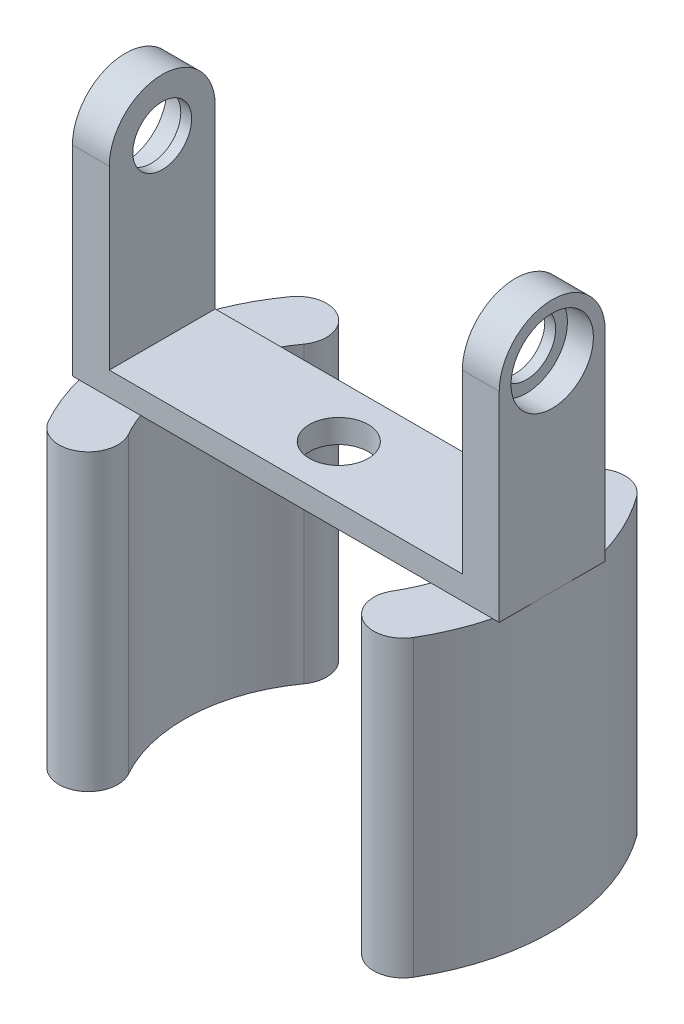
from build123d import *

# Parameters (mm, degrees)
SKETCH1_R           = 9
SKETCH1_R_2         = 5
BOSS_EXTRUDE1_DEPTH = 6.26
BOSS_EXTRUDE2_DEPTH = 6.26
SKETCH2_R           = 7
CUT_EXTRUDE1_DEPTH  = 4.41
SKETCH4_W           = 36.26
SKETCH4_H           = 18
BOSS_EXTRUDE3_DEPTH = 4
SKETCH5_R           = 5
CUT_EXTRUDE2_DEPTH  = 5
BOSS_EXTRUDE4_DEPTH = 50


with BuildPart() as part:
    # Sketch1 → Boss-Extrude1 (new body)
    with BuildSketch(Plane(origin=(0, 0, 0), x_dir=(0, 0, -1), z_dir=(1, 0, 0))):
        Circle(SKETCH1_R)
        Circle(SKETCH1_R_2, mode=Mode.SUBTRACT)
    extrude(amount=BOSS_EXTRUDE1_DEPTH)

    # Sketch3 → Boss-Extrude2 (add)
    with BuildSketch(Plane.ZY):
        with BuildLine():
            Line((-9, 0), (-9, -30))
            Line((-9, -30), (9, -30))
            Line((9, -30), (9, 0))
            Line((9, 0), (5, 0))
            ThreePointArc((5, 0), (0, -5), (-5, 0))
            Line((-5, 0), (-9, 0))
        make_face()
    extrude(amount=-BOSS_EXTRUDE2_DEPTH)

    # Sketch2 → Cut-Extrude1 (cut)
    with BuildSketch(Plane(origin=(6.26, 0, 0), x_dir=(0, 0, -1), z_dir=(1, 0, 0))):
        Circle(SKETCH2_R)
    extrude(amount=-CUT_EXTRUDE1_DEPTH, mode=Mode.SUBTRACT)

    # Sketch4 → Boss-Extrude3 (add)
    with BuildSketch(Plane.XZ.offset(30)):
        with Locations((-11.87, 0)):
            Rectangle(SKETCH4_W, SKETCH4_H)
    extrude(amount=BOSS_EXTRUDE3_DEPTH)

    # Mirror2: part across plane


with BuildPart() as part_1:
    add(part.part)
    add(part.part.mirror(Plane(origin=(-30, -34, 9), x_dir=(0, 0, 1), z_dir=(1, 0, 0))))

    # Sketch5 → Cut-Extrude2 (cut, through all)
    with BuildSketch(Plane(origin=(0, -30, 0), x_dir=(1, 0, 0), z_dir=(0, 1, 0))):
        with Locations((-30, 0)):
            Circle(SKETCH5_R)
    extrude(amount=-CUT_EXTRUDE2_DEPTH, mode=Mode.SUBTRACT)

    # Sketch6 → Boss-Extrude4 (add)
    with BuildSketch(Plane.XZ.offset(34)):
        with BuildLine():
            ThreePointArc((1.184711928, 18.501387568), (6.224007517, -1.615202581), (-0.585698563, -21.203454222))
            ThreePointArc((-0.585698563, -21.203454222), (-7.565532493, -22.335672537), (-8.697750807, -15.355838607))
            ThreePointArc((-8.697750807, -15.355838607), (-3.76606626, -1.169752338), (-7.415594726, 13.39896408))
            ThreePointArc((-7.415594726, 13.39896408), (-5.666653143, 20.250329151), (1.184711928, 18.501387568))
        make_face()
        with BuildLine():
            ThreePointArc((-61.638666525, 17.713903593), (-66.200917241, -2.069103891), (-59.414301437, -21.203454222))
            ThreePointArc((-59.414301437, -21.203454222), (-52.434467507, -22.335672537), (-51.302249193, -15.355838607))
            ThreePointArc((-51.302249193, -15.355838607), (-56.217211438, -1.498474026), (-52.913165553, 12.828657153))
            ThreePointArc((-52.913165553, 12.828657153), (-54.833292819, 19.634030859), (-61.638666525, 17.713903593))
        make_face()
    extrude(amount=BOSS_EXTRUDE4_DEPTH)


solid = part_1.part
